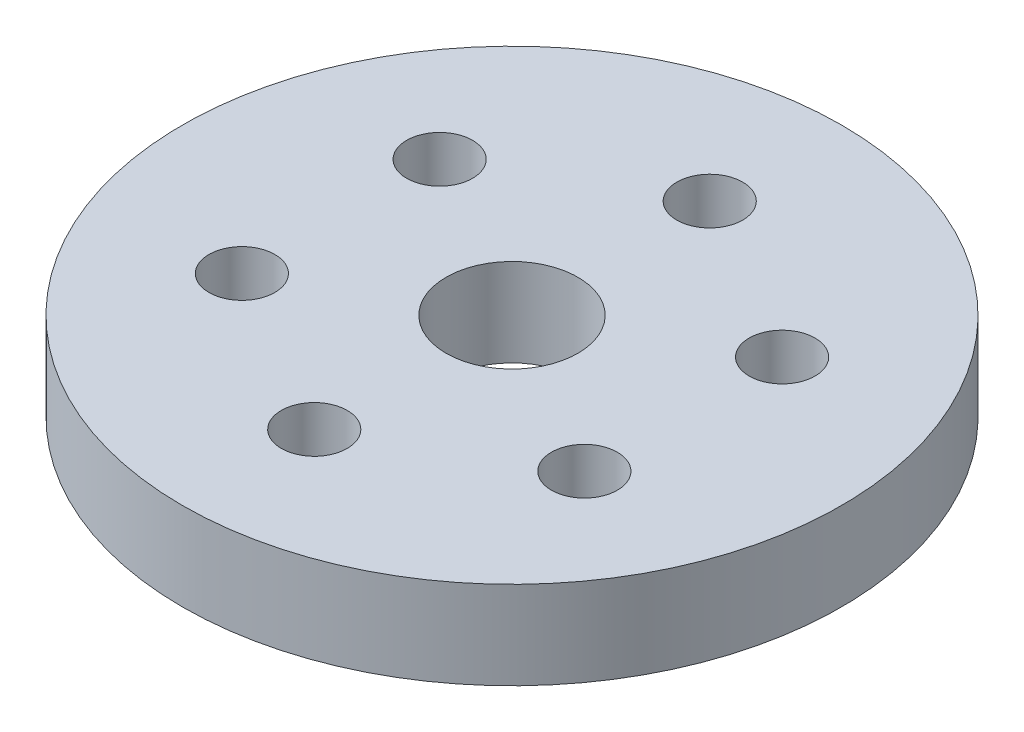
from build123d import *

# Parameters (mm, degrees)
SKETCH1_R               = 15.875
SKETCH1_R_2             = 3.175
BOSS_EXTRUDE1_DEPTH     = 2.116666667
SKETCH2_R               = 1.5875
CUT_EXTRUDE1_DEPTH      = 3.116666667
CUT_EXTRUDE1_DEPTH_BACK = 3.116666667


with BuildPart() as part:
    # Sketch1 → Boss-Extrude1 (new body, symmetric)
    with BuildSketch(Plane(origin=(0, 0, 0), x_dir=(1, 0, 0), z_dir=(0, 1, 0))):
        Circle(SKETCH1_R)
        Circle(SKETCH1_R_2, mode=Mode.SUBTRACT)
    extrude(amount=BOSS_EXTRUDE1_DEPTH, both=True)

    # Sketch2 → Cut-Extrude1 (cut, two sides)
    with BuildSketch(Plane(origin=(0, 0, 0), x_dir=(1, 0, 0), z_dir=(0, 1, 0))) as cut_extrude1_sk:
        with Locations((0, 9.525)):
            Circle(SKETCH2_R)
        with Locations((8.248891971, 4.7625)):
            Circle(SKETCH2_R)
        with Locations((8.248891971, -4.7625)):
            Circle(SKETCH2_R)
        with Locations((0, -9.525)):
            Circle(SKETCH2_R)
        with Locations((-8.248891971, -4.7625)):
            Circle(SKETCH2_R)
        with Locations((-8.248891971, 4.7625)):
            Circle(SKETCH2_R)
    extrude(amount=CUT_EXTRUDE1_DEPTH, mode=Mode.SUBTRACT)
    extrude(cut_extrude1_sk.sketch, amount=-CUT_EXTRUDE1_DEPTH_BACK, mode=Mode.SUBTRACT)


solid = part.part
